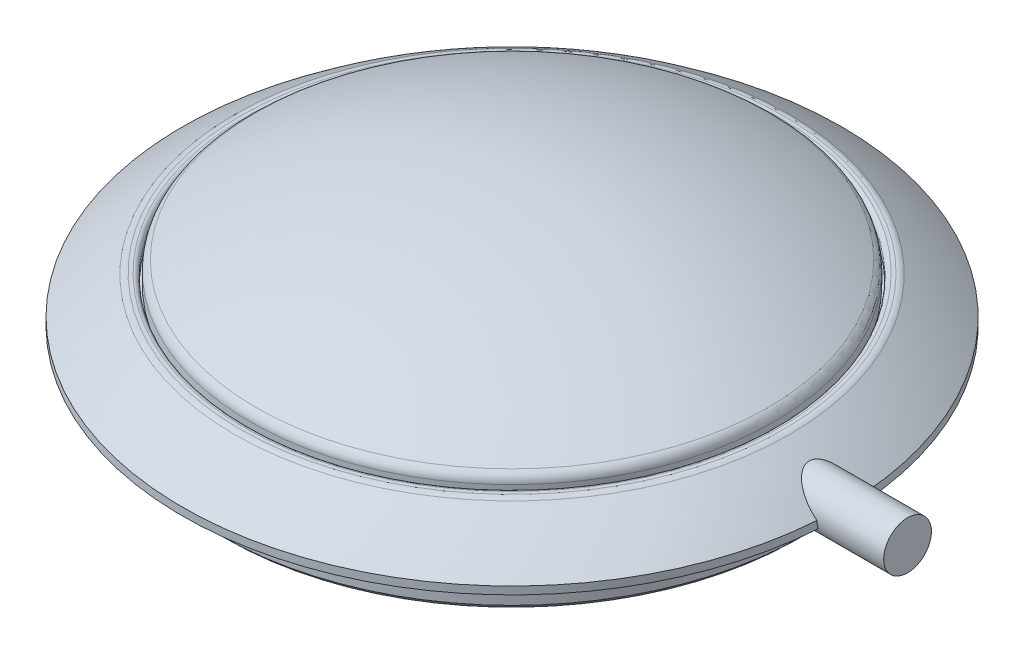
from build123d import *

# Parameters (mm, degrees)
SKETCH_1_R           = 30
EXTRUDE_1_DEPTH      = 15
SKETCH_2_OUTSIDE_W   = 79.234
SKETCH_2_OUTSIDE_H   = 79.234
SKETCH_2_OUTSIDE_R   = 27.5
CUT_EXTRUDE_1_DEPTH  = 3.8
SKETCH_2_3_OUTSIDE_W = 79.234
SKETCH_2_3_OUTSIDE_H = 79.234
SKETCH_2_3_OUTSIDE_R = 26.5
CUT_EXTRUDE_2_DEPTH  = 3.3
EXTRUDE_2_DEPTH      = 36
CHAMFER_1_SIZE       = 0.5
FILLET_1_R           = 1
FILLET_2_R           = 0.4


with BuildPart() as part:
    # Эскиз1 → Бобышка-Вытянуть1 (new body)
    with BuildSketch(Plane(origin=(0, 0, 0), x_dir=(1, 0, 0), z_dir=(0, 1, 0))):
        Circle(SKETCH_1_R)
    extrude(amount=EXTRUDE_1_DEPTH)

    # Эскиз2 outside → Вырез-Вытянуть1 (cut)
    with BuildSketch(Plane(origin=(0, 0, 0), x_dir=(1, 0, 0), z_dir=(0, 1, 0))):
        Rectangle(SKETCH_2_OUTSIDE_W, SKETCH_2_OUTSIDE_H)
        Circle(SKETCH_2_OUTSIDE_R, mode=Mode.SUBTRACT)
    extrude(amount=CUT_EXTRUDE_1_DEPTH, mode=Mode.SUBTRACT)

    # Эскиз2<3> outside → Вырез-Вытянуть2 (cut)
    with BuildSketch(Plane(origin=(0, 0, 0), x_dir=(1, 0, 0), z_dir=(0, 1, 0))):
        Rectangle(SKETCH_2_3_OUTSIDE_W, SKETCH_2_3_OUTSIDE_H)
        Circle(SKETCH_2_3_OUTSIDE_R, mode=Mode.SUBTRACT)
    extrude(amount=CUT_EXTRUDE_2_DEPTH, mode=Mode.SUBTRACT)

    # Эскиз3 → Вырез-Повернуть1 (revolve, cut)
    with BuildSketch(Plane.XY):
        with BuildLine():
            Line((-42.194966184, 4.5), (-30, 4.5))
            ThreePointArc((-30, 4.5), (-27.555432596, 6.326286214), (-25, 7.993917882))
            Line((-25, 7.993917882), (-24, 7.993917882))
            Line((-24, 7.993917882), (-24, 6.993917882))
            Line((-24, 6.993917882), (-23.8, 6.993917882))
            Line((-23.8, 6.993917882), (-23.8, 8.700239193))
            ThreePointArc((-23.8, 8.700239193), (-12.309823173, 13.398399257), (0, 15))
            Line((0, 15), (0, 24.071462315))
            Line((0, 24.071462315), (-42.194966184, 24.071462315))
            Line((-42.194966184, 24.071462315), (-42.194966184, 4.5))
        make_face()
    revolve(axis=Axis((0, 0, 0), (0, 1, 0)), mode=Mode.SUBTRACT)

    # Эскиз4 → Бобышка-Вытянуть2 (add)
    with BuildSketch(Plane(origin=(0, 0, 0), x_dir=(0, 0, -1), z_dir=(1, 0, 0))):
        with BuildLine():
            ThreePointArc((0, 2.325), (1.537957249, 2.962042751), (2.175, 4.5))
            ThreePointArc((2.175, 4.5), (-1.537957249, 6.037957249), (0, 2.325))
        make_face()
    extrude(amount=EXTRUDE_2_DEPTH)

    # Фаска1
    chamfer_1_edges = [part.edges().sort_by_distance(p)[0] for p in [
        (-26.5, 0, 0),
    ]]
    chamfer(chamfer_1_edges, length=CHAMFER_1_SIZE)

    # Скругление1
    fillet_1_edges = [part.edges().sort_by_distance(p)[0] for p in [
        (23.8, 8.700239193, 0),
        (25, 7.993917882, 0),
    ]]
    fillet(fillet_1_edges, radius=FILLET_1_R)

    # Скругление2
    fillet_2_edges = [part.edges().sort_by_distance(p)[0] for p in [
        (24, 7.993917882, 0),
    ]]
    fillet(fillet_2_edges, radius=FILLET_2_R)


solid = part.part
